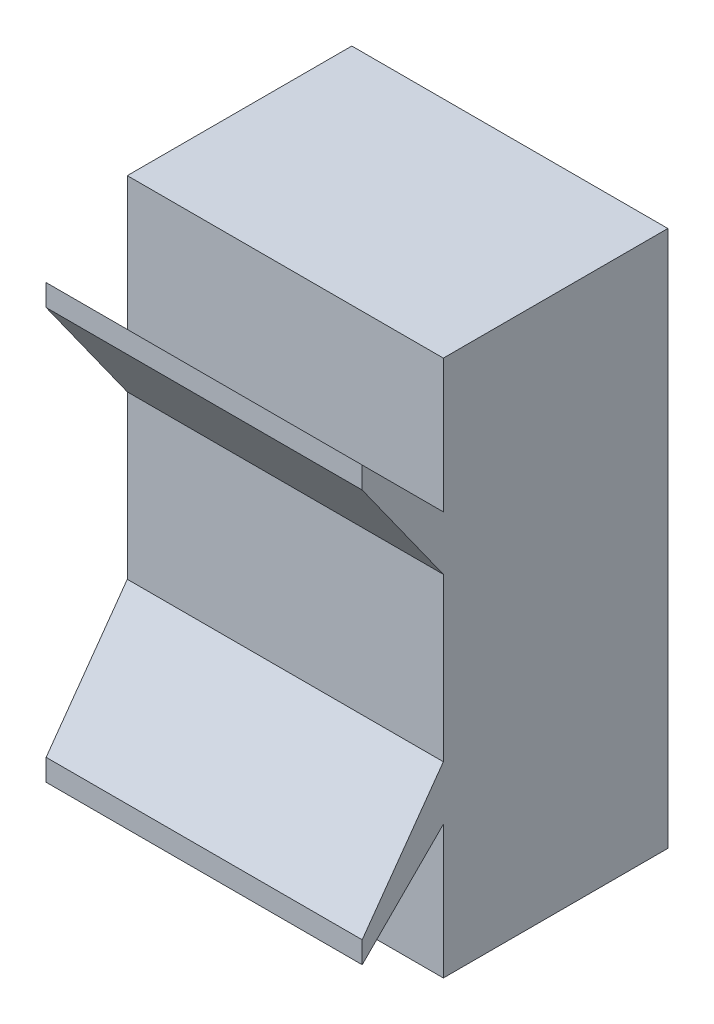
from build123d import *

# Parameters (mm, degrees)
BODY_BASE_SKETCH_W = 5.842496399
BODY_BASE_SKETCH_H = 9.923586627
BODY_BASE_DEPTH    = 4.15
PCB_SPRING_DEPTH   = 5.842496


with BuildPart() as part:
    # Body Base Sketch → Body Base (new body)
    with BuildSketch(Plane.XY):
        with Locations((11.813574268, 26.319994646)):
            Rectangle(BODY_BASE_SKETCH_W, BODY_BASE_SKETCH_H)
    extrude(amount=BODY_BASE_DEPTH)

    # PCB Spring Sketch → PCB Spring (add)
    with BuildSketch(Plane(origin=(14.734822467, 0, 0), x_dir=(0, 0, -1), z_dir=(1, 0, 0))):
        Polygon((-4.15, 24.819994645), (-4.15, 23.819994645), (-5.65, 22.319994645), (-5.65, 22.719994645), align=None)
        Polygon((-5.65, 29.919994645), (-5.65, 30.319994645), (-4.15, 28.819994645), (-4.15, 27.819994645), align=None)
    extrude(amount=-PCB_SPRING_DEPTH)


solid = part.part
